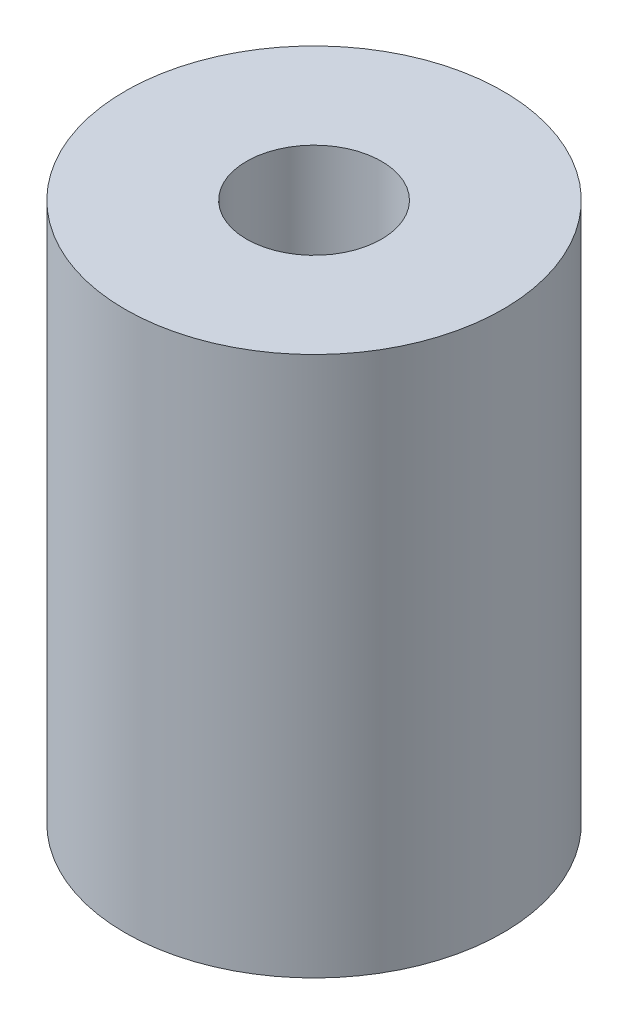
from build123d import *

# Parameters (mm, degrees)
SKETCH1_R           = 3.5
SKETCH1_R_2         = 1
BOSS_EXTRUDE1_DEPTH = 5
M3_TAPPED_HOLE1_D   = 2.5


with BuildPart() as part:
    # Sketch1 → Boss-Extrude1 (new body, symmetric)
    with BuildSketch(Plane(origin=(0, 0, 0), x_dir=(1, 0, 0), z_dir=(0, 1, 0))):
        Circle(SKETCH1_R)
        Circle(SKETCH1_R_2, mode=Mode.SUBTRACT)
    extrude(amount=BOSS_EXTRUDE1_DEPTH, both=True)

    # M3 Tapped Hole1 (through all)
    with Locations(Plane(origin=(0, 5, 0), x_dir=(1, 0, 0), z_dir=(0, 1, 0))):
        with Locations((0, 0)):
            Hole(M3_TAPPED_HOLE1_D / 2)


solid = part.part
